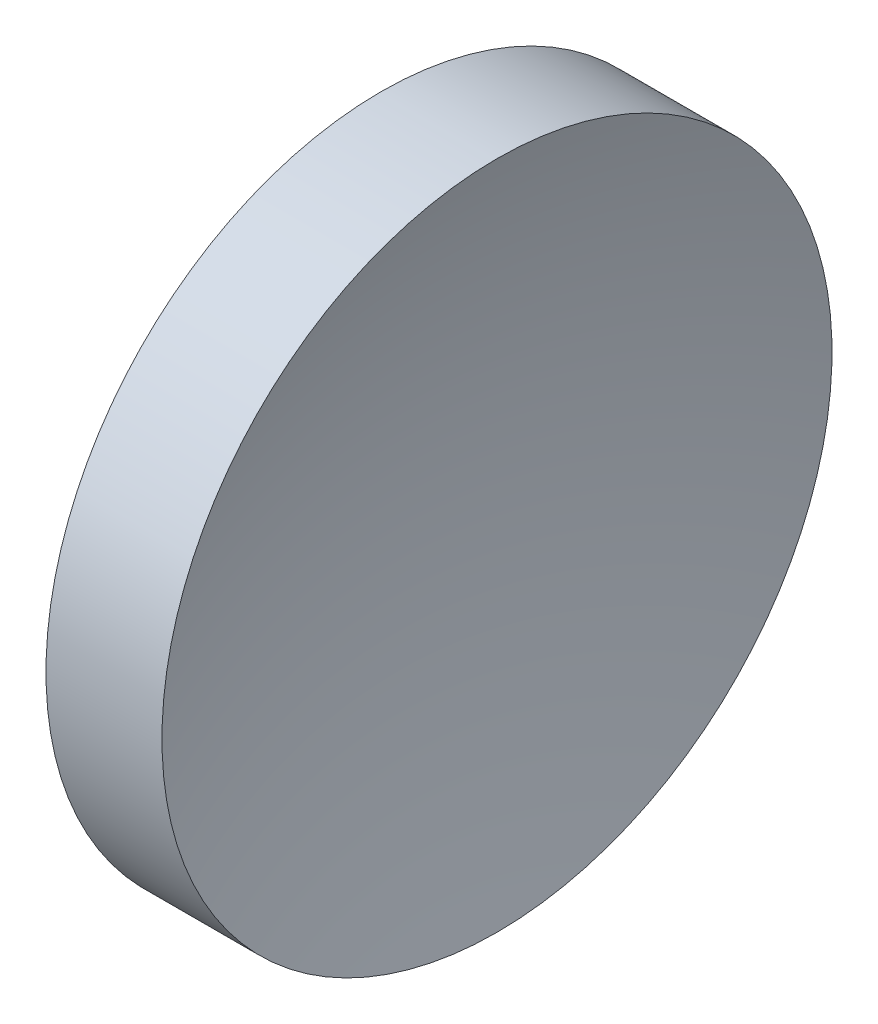
from build123d import *


with BuildPart() as part:
    # 草图1 → 旋转1 (revolve)
    with BuildSketch(Plane.XY, mode=Mode.PRIVATE) as revolve_1_sk:
        with BuildLine():
            Line((44.854422626, 26.062252183), (44.854422626, 34.062252183))
            Line((44.854422626, 34.062252183), (47.624001384, 34.062252183))
            ThreePointArc((47.624001384, 34.062252183), (46.673790925, 30.112308671), (46.354422626, 26.062252183))
            Line((46.354422626, 26.062252183), (44.854422626, 26.062252183))
        make_face()
    revolve(revolve_1_sk.sketch.rotate(Axis((43.011950236, 26.062252183, 0), (1, 0, 0)), 180), axis=Axis((43.011950236, 26.062252183, 0), (1, 0, 0)))  # turned: the seam where the file's is


solid = part.part
